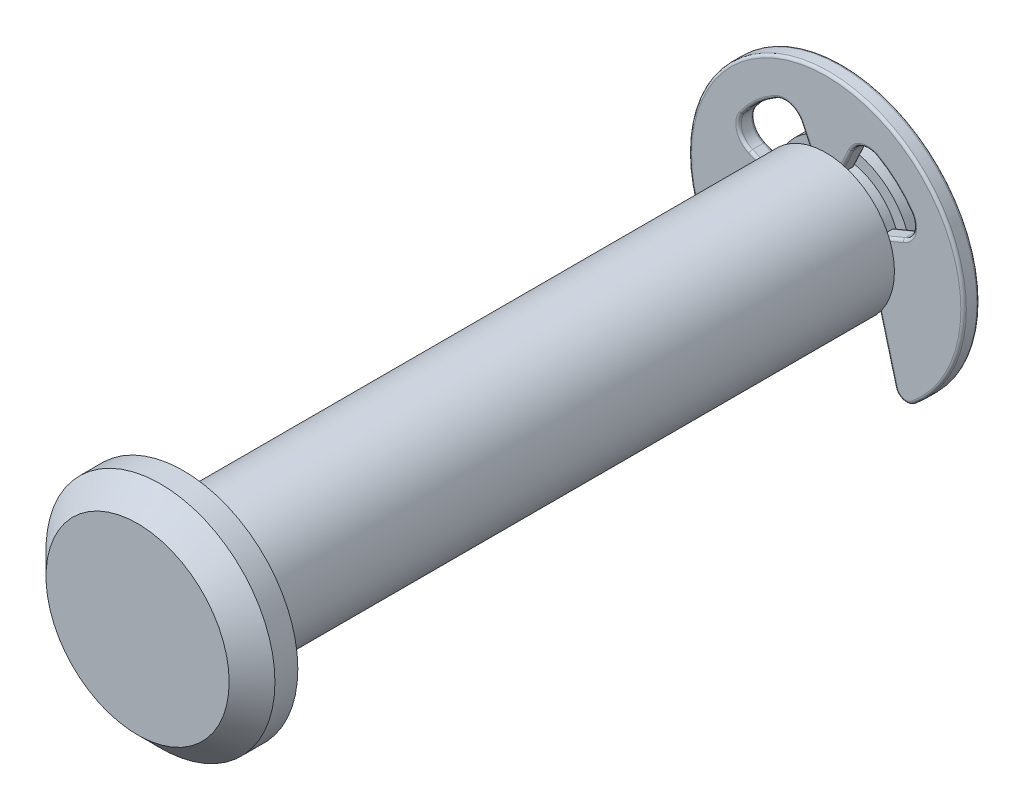
from build123d import *

# Parameters (mm, degrees)
BOSS_EXTRUDE1_DEPTH      = 0.35
BOSS_EXTRUDE1_DEPTH_BACK = 0.35
FILLET1_R                = 0.12
CHAMFER1_SIZE            = 0.6


with BuildPart() as part:
    # Sketch2 → Revolve1 (revolve)
    with BuildSketch(Plane(origin=(0, 0, 0), x_dir=(0, 0, -1), z_dir=(1, 0, 0))):
        Polygon((15, 3), (15, 0), (-17, 0), (-17, 4), (-16, 5), (-15, 5), (-15, 3), (13.06, 3), (13.06, 2.5), (13.8, 2.5), (13.8, 3), align=None)
    revolve(axis=Axis((0, 0, 15), (0, 0, -1)))

    # Chamfer1
    chamfer1_edges = [part.edges().sort_by_distance(p)[0] for p in [
        (0, -3, -15),
    ]]
    chamfer(chamfer1_edges, length=CHAMFER1_SIZE)


with BuildPart() as body_2:
    # Sketch3 → Boss-Extrude1 (new body, two sides)
    with BuildSketch(Plane(origin=(0, 0, -13.43), x_dir=(-1, 0, 0), z_dir=(0, 0, -1))) as boss_extrude1_sk:
        with BuildLine():
            ThreePointArc((-2.211302211, 3.919201772), (-1.573842768, 3.984228004), (-1.093135589, 3.5605494))
            Line((-1.093135589, 3.5605494), (-0.568095803, 2.434597946))
            ThreePointArc((-0.568095803, 2.434597946), (0, 2.5), (0.568095803, 2.434597946))
            Line((0.568095803, 2.434597946), (1.093135589, 3.5605494))
            ThreePointArc((1.093135589, 3.5605494), (1.573842768, 3.984228004), (2.211302211, 3.919201772))
            ThreePointArc((2.211302211, 3.919201772), (3.024074317, 3.332412718), (3.686774698, 2.580250438))
            ThreePointArc((3.686774698, 2.580250438), (3.799362352, 1.89758817), (3.337494831, 1.382435623))
            Line((3.337494831, 1.382435623), (2.309698831, 0.956708581))
            ThreePointArc((2.309698831, 0.956708581), (2.451963201, 0.487725805), (2.5, 0))
            ThreePointArc((2.5, 0), (2.41386496, -0.650581242), (2.161395238, -1.256332211))
            Line((2.161395238, -1.256332211), (3, -4.386047791))
            ThreePointArc((3, -4.386047791), (3.329664547, -4.732558021), (3.799595905, -4.643605383))
            ThreePointArc((3.799595905, -4.643605383), (5.422064894, -2.569282445), (6, 0))
            ThreePointArc((6, 0), (-2.569282445, 5.422064894), (-3.799595905, -4.643605383))
            ThreePointArc((-3.799595905, -4.643605383), (-3.329664547, -4.732558021), (-3, -4.386047791))
            Line((-3, -4.386047791), (-2.161395238, -1.256332211))
            ThreePointArc((-2.161395238, -1.256332211), (-2.494405326, -0.167158813), (-2.309698831, 0.956708581))
            Line((-2.309698831, 0.956708581), (-3.337494831, 1.382435623))
            ThreePointArc((-3.337494831, 1.382435623), (-3.799362352, 1.89758817), (-3.686774698, 2.580250438))
            ThreePointArc((-3.686774698, 2.580250438), (-3.024074317, 3.332412718), (-2.211302211, 3.919201772))
        make_face()
    extrude(amount=BOSS_EXTRUDE1_DEPTH)
    extrude(boss_extrude1_sk.sketch, amount=-BOSS_EXTRUDE1_DEPTH_BACK)

    # Fillet1
    fillet1_edges = [body_2.edges().sort_by_distance(p)[0] for p in [
        (3.329664547, -4.732558021, -13.78),
        (2.580697619, -2.821190001, -13.78),
        (2.494405326, -0.167158813, -13.78),
        (2.823596831, 1.169572102, -13.78),
        (3.799362352, 1.89758817, -13.78),
        (3.024074317, 3.332412718, -13.78),
        (1.573842768, 3.984228004, -13.78),
        (0.830615696, 2.997573673, -13.78),
        (0, 2.5, -13.78),
        (-3.329664547, -4.732558021, -13.08),
        (-2.580697619, -2.821190001, -13.08),
        (-2.823596831, 1.169572102, -13.08),
        (-0.830615696, 2.997573673, -13.08),
        (-3.329664547, -4.732558021, -13.78),
        (-0.830615696, 2.997573673, -13.78),
        (0.830615696, 2.997573673, -13.08),
        (2.823596831, 1.169572102, -13.08),
        (2.580697619, -2.821190001, -13.08),
        (-1.573842768, 3.984228004, -13.78),
        (3.329664547, -4.732558021, -13.08),
        (0, 6, -13.08),
        (-2.494405326, -0.167158813, -13.08),
        (-3.799362352, 1.89758817, -13.08),
        (-3.024074317, 3.332412718, -13.08),
        (-1.573842768, 3.984228004, -13.08),
        (0, 2.5, -13.08),
        (1.573842768, 3.984228004, -13.08),
        (3.024074317, 3.332412718, -13.08),
        (-3.024074317, 3.332412718, -13.78),
        (3.799362352, 1.89758817, -13.08),
        (2.494405326, -0.167158813, -13.08),
        (-3.799362352, 1.89758817, -13.78),
        (-2.823596831, 1.169572102, -13.78),
        (-2.494405326, -0.167158813, -13.78),
        (-2.580697619, -2.821190001, -13.78),
        (0, 6, -13.78),
    ]]
    fillet(fillet1_edges, radius=FILLET1_R)


solid = Compound([part.part, body_2.part])
